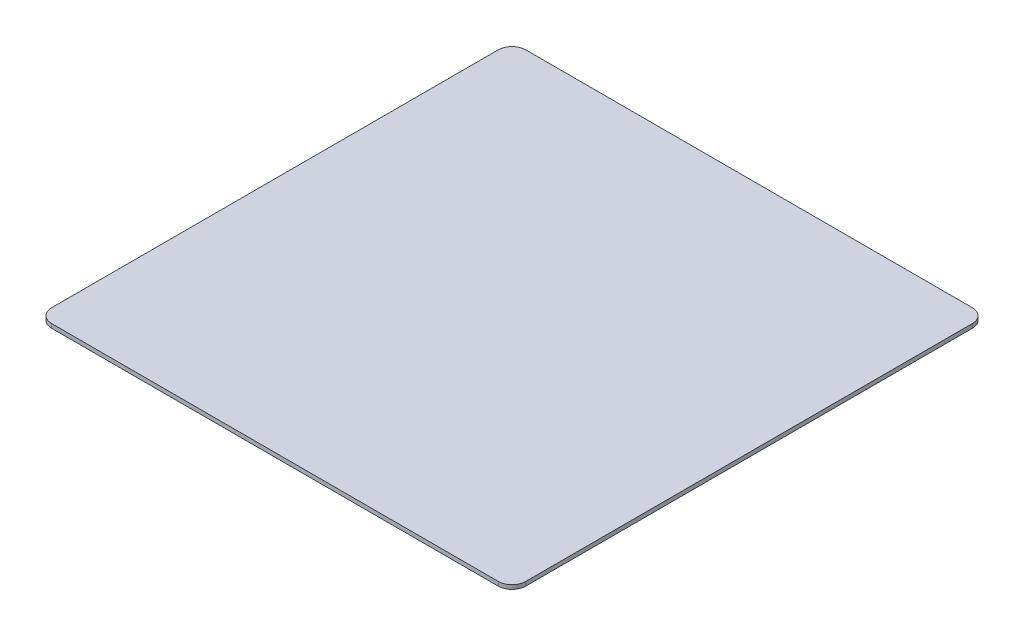
from build123d import *

# Parameters (mm, degrees)
BOSS_EXTRUDE1_DEPTH = 0.6


with BuildPart() as part:
    # Sketch1 → Boss-Extrude1 (new body)
    with BuildSketch(Plane(origin=(0, 0, 0), x_dir=(1, 0, 0), z_dir=(0, 1, 0))):
        with BuildLine():
            Line((-32.5, -34.5), (32.5, -34.5))
            ThreePointArc((32.5, -34.5), (33.914213562, -33.914213562), (34.5, -32.5))
            Line((34.5, -32.5), (34.5, 32.5))
            ThreePointArc((34.5, 32.5), (33.914213562, 33.914213562), (32.5, 34.5))
            Line((32.5, 34.5), (-32.5, 34.5))
            ThreePointArc((-32.5, 34.5), (-33.914213562, 33.914213562), (-34.5, 32.5))
            Line((-34.5, 32.5), (-34.5, -32.5))
            ThreePointArc((-34.5, -32.5), (-33.914213562, -33.914213562), (-32.5, -34.5))
        make_face()
    extrude(amount=BOSS_EXTRUDE1_DEPTH)


solid = part.part
